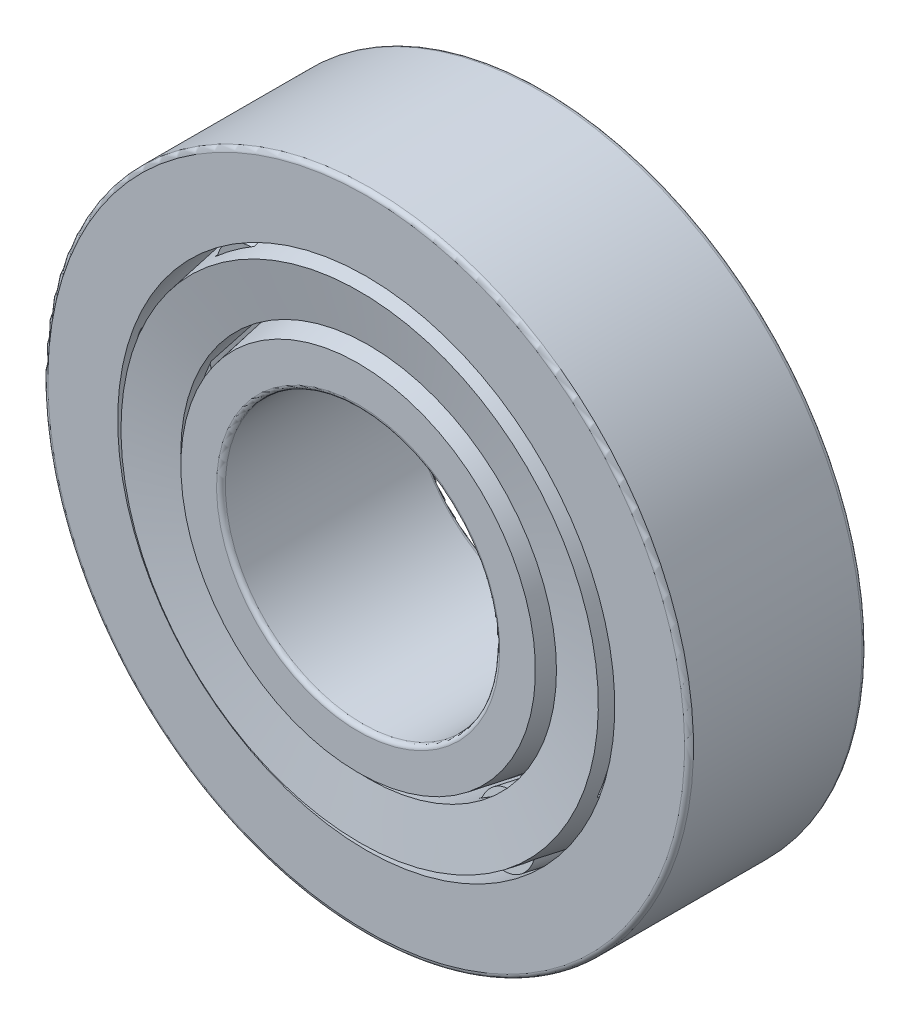
from build123d import *

# Parameters (mm, degrees)
CIRPATTERN1_COUNT = 10
CIRPATTERN2_COUNT = 10
CIRPATTERN2_ANGLE = 324
FILLET1_R         = 0.275
FILLET2_R         = 0.275


with BuildPart() as part:
    # Sketch1 → Revolve1 (revolve)
    with BuildSketch(Plane(origin=(0, 0, 0), x_dir=(0, 0, -1), z_dir=(1, 0, 0))):
        Polygon((-5.5, 20), (5.5, 20), (5.5, 17.339596788), (-5.5, 15.4), align=None)
    revolve(axis=Axis((0, 0, 6), (0, 0, -1)))

    # Fillet1
    fillet1_edges = [part.edges().sort_by_distance(p)[0] for p in [
        (0, -20, -5.5),
        (0, -20, 5.5),
    ]]
    fillet(fillet1_edges, radius=FILLET1_R)


with BuildPart() as body_2:
    # Sketch5 → Revolve4 (revolve)
    with BuildSketch(Plane(origin=(0, 0, 0), x_dir=(0, 0, -1), z_dir=(1, 0, 0))):
        Polygon((6, 13.1), (-6, 10.984076231), (-6, 8.5), (6, 8.5), align=None)
    revolve(axis=Axis((0, 0, 6), (0, 0, -1)))

    # Fillet2
    fillet2_edges = [body_2.edges().sort_by_distance(p)[0] for p in [
        (0, -8.5, 6),
        (0, -8.5, -6),
    ]]
    fillet(fillet2_edges, radius=FILLET2_R)


with BuildPart() as body_3:
    # Sketch2 → Revolve2 (revolve)
    with BuildSketch(Plane(origin=(0, 0, 0), x_dir=(0, 0, -1), z_dir=(1, 0, 0))):
        Polygon((-5.907488676, 14.787178717), (-5.352420729, 11.639231964), (5.5, 13.552806544), (7.157488676, 13.845066518), (6.602420729, 16.993013272), (5.5, 16.798626753), align=None)
    revolve(axis=Axis((0, 0, 6), (0, 0, -1)))

    # Sketch3 → Cut-Revolve1 (revolve, cut)
    with BuildSketch(Plane(origin=(0, 0, 0), x_dir=(0, 0, -1), z_dir=(1, 0, 0))):
        Polygon((-5, 15.48816349), (-4.629954702, 13.389532321), (5.5, 15.175716649), (5.129954702, 17.274347818), align=None)
    cut_revolve1 = revolve(axis=Axis((0, 13.213205341, 5.629954702), (0, 0.173648178, -0.984807753)), mode=Mode.SUBTRACT)

    # CirPattern1: Cut-Revolve1 ×10 about axis
    cirpattern1_axis = Axis((0, 0, 0), (0, 0, 1))
    for i in range(1, CIRPATTERN1_COUNT):
        add(cut_revolve1.rotate(cirpattern1_axis, i * 360 / CIRPATTERN1_COUNT), mode=Mode.SUBTRACT)


with BuildPart() as body_4:
    # Sketch4 → Revolve3 (revolve)
    with BuildSketch(Plane(origin=(0, 0, 0), x_dir=(0, 0, -1), z_dir=(1, 0, 0))):
        Polygon((-4.977946681, 15.363092906), (5.152008021, 17.149277233), (5.5, 15.175716649), (-4.629954702, 13.389532321), align=None)
    revolve(axis=Axis((0, 13.213205341, 5.629954702), (0, 0.173648178, -0.984807753)))


with BuildPart() as cirpattern2_1:
    # CirPattern2: pattern copy
    add(body_4.part.rotate(Axis((0, 0, -6), (0, 0, 1)), 1 * CIRPATTERN2_ANGLE / (CIRPATTERN2_COUNT - 1)))


with BuildPart() as cirpattern2_2:
    # CirPattern2: pattern copy
    add(body_4.part.rotate(Axis((0, 0, -6), (0, 0, 1)), 2 * CIRPATTERN2_ANGLE / (CIRPATTERN2_COUNT - 1)))


with BuildPart() as cirpattern2_3:
    # CirPattern2: pattern copy
    add(body_4.part.rotate(Axis((0, 0, -6), (0, 0, 1)), 3 * CIRPATTERN2_ANGLE / (CIRPATTERN2_COUNT - 1)))


with BuildPart() as cirpattern2_4:
    # CirPattern2: pattern copy
    add(body_4.part.rotate(Axis((0, 0, -6), (0, 0, 1)), 4 * CIRPATTERN2_ANGLE / (CIRPATTERN2_COUNT - 1)))


with BuildPart() as cirpattern2_5:
    # CirPattern2: pattern copy
    add(body_4.part.rotate(Axis((0, 0, -6), (0, 0, 1)), 5 * CIRPATTERN2_ANGLE / (CIRPATTERN2_COUNT - 1)))


with BuildPart() as cirpattern2_6:
    # CirPattern2: pattern copy
    add(body_4.part.rotate(Axis((0, 0, -6), (0, 0, 1)), 6 * CIRPATTERN2_ANGLE / (CIRPATTERN2_COUNT - 1)))


with BuildPart() as cirpattern2_7:
    # CirPattern2: pattern copy
    add(body_4.part.rotate(Axis((0, 0, -6), (0, 0, 1)), 7 * CIRPATTERN2_ANGLE / (CIRPATTERN2_COUNT - 1)))


with BuildPart() as cirpattern2_8:
    # CirPattern2: pattern copy
    add(body_4.part.rotate(Axis((0, 0, -6), (0, 0, 1)), 8 * CIRPATTERN2_ANGLE / (CIRPATTERN2_COUNT - 1)))


with BuildPart() as cirpattern2_9:
    # CirPattern2: pattern copy
    add(body_4.part.rotate(Axis((0, 0, -6), (0, 0, 1)), 9 * CIRPATTERN2_ANGLE / (CIRPATTERN2_COUNT - 1)))


solid = Compound([part.part, body_2.part, body_3.part, body_4.part, cirpattern2_1.part, cirpattern2_2.part, cirpattern2_3.part, cirpattern2_4.part, cirpattern2_5.part, cirpattern2_6.part, cirpattern2_7.part, cirpattern2_8.part, cirpattern2_9.part])
